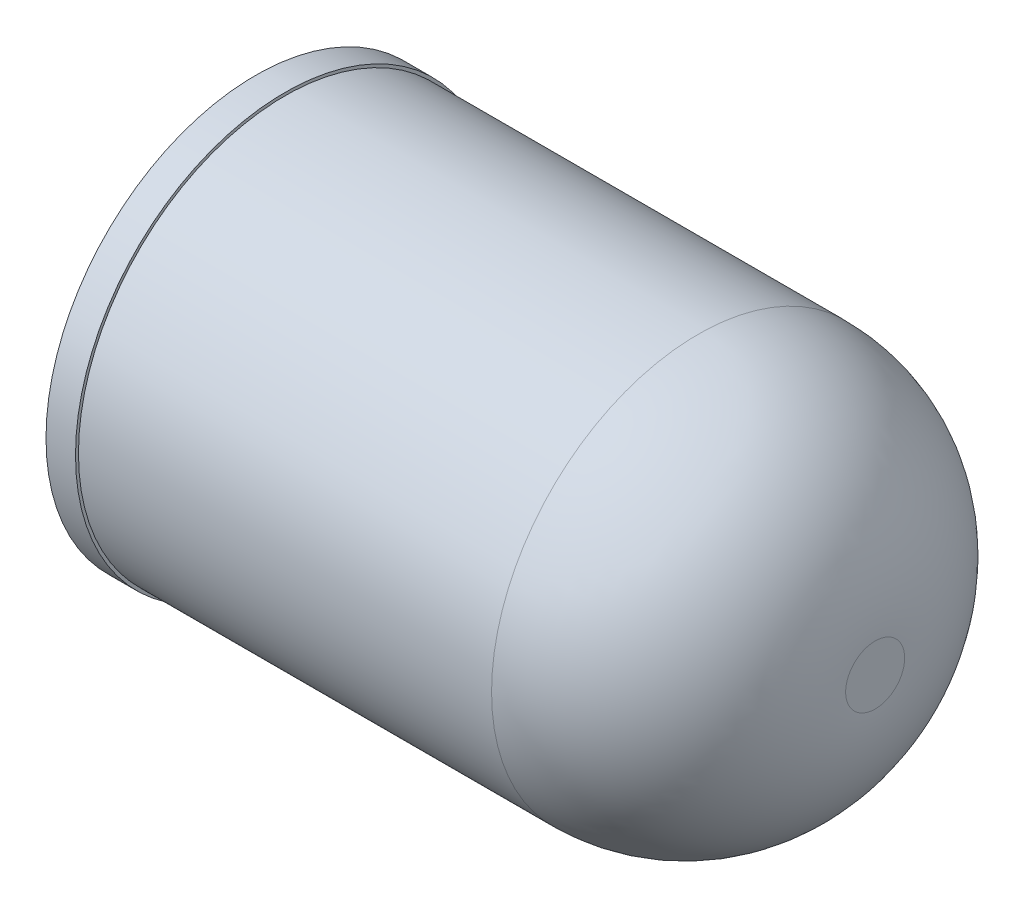
from build123d import *

# Parameters (mm, degrees)
CROQUIS1_R              = 3.5
SALIENTE_EXTRUIR1_DEPTH = 10
REDONDEO1_R             = 3
CROQUIS2_R              = 3.55
SALIENTE_EXTRUIR2_DEPTH = 0.5


with BuildPart() as part:
    # Croquis1 → Saliente-Extruir1 (new body)
    with BuildSketch(Plane(origin=(0, 0, 0), x_dir=(0, 0, -1), z_dir=(1, 0, 0))):
        Circle(CROQUIS1_R)
    extrude(amount=SALIENTE_EXTRUIR1_DEPTH)

    # Redondeo1
    redondeo1_edges = [part.edges().sort_by_distance(p)[0] for p in [
        (10, 0, 3.5),
    ]]
    fillet(redondeo1_edges, radius=REDONDEO1_R)

    # Croquis2 → Saliente-Extruir2 (add)
    with BuildSketch(Plane.ZY):
        Circle(CROQUIS2_R)
    extrude(amount=SALIENTE_EXTRUIR2_DEPTH)


solid = part.part
